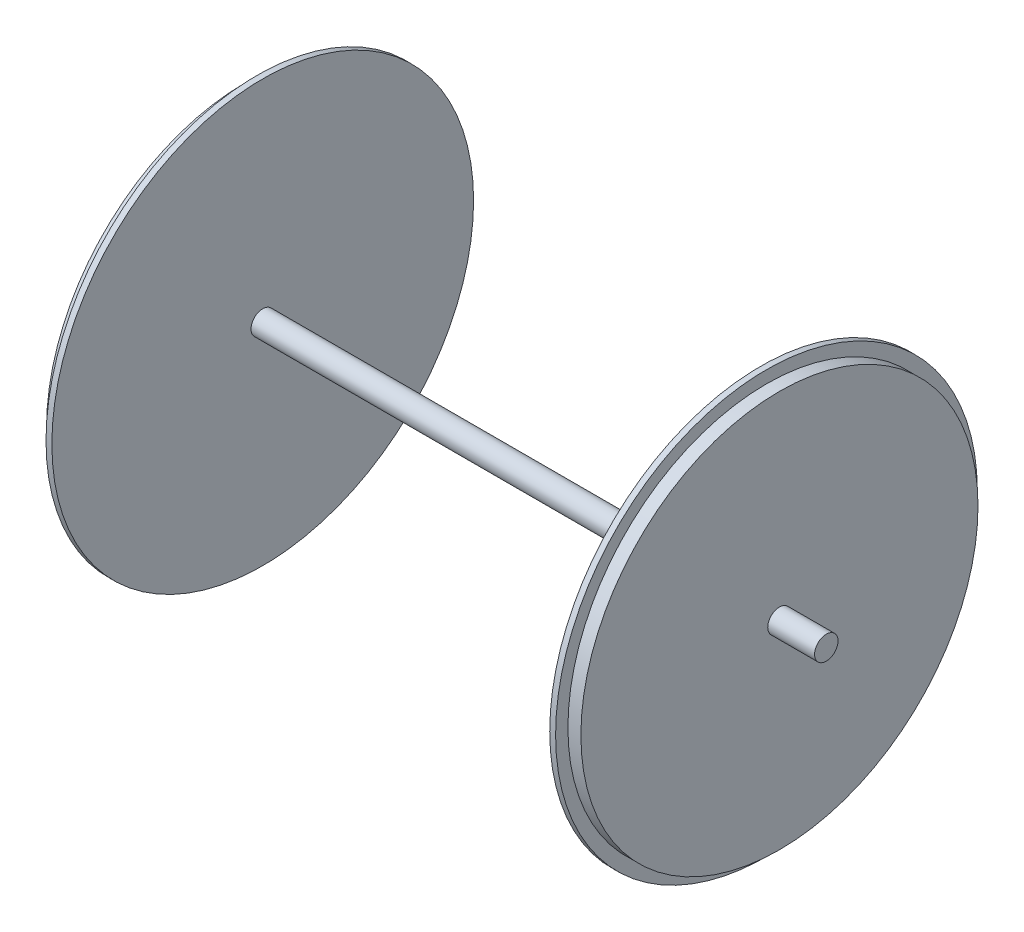
from build123d import *


with BuildPart() as part:
    # Sketch1 → Revolve2 (revolve)
    with BuildSketch(Plane.XY):
        Polygon((-2977.315417146, 50.8), (-818.315417146, 50.8), (-818.315417146, 914.4), (-792.915417146, 914.4), (-792.915417146, 861.011549077), (-736.6, 861.011549077), (-736.6, 50.8), (-533.4, 50.8), (-533.4, 0), (-736.6, 0), (-3053.515417146, 0), (-3256.715417146, 0), (-3256.715417146, 50.8), (-3053.515417146, 50.8), (-3053.515417146, 861.011549077), (-3002.715417146, 861.011549077), (-3002.715417146, 914.4), (-2977.315417146, 914.4), align=None)
    revolve(axis=Axis((-3053.515417146, 0, 0), (1, 0, 0)))


solid = part.part
